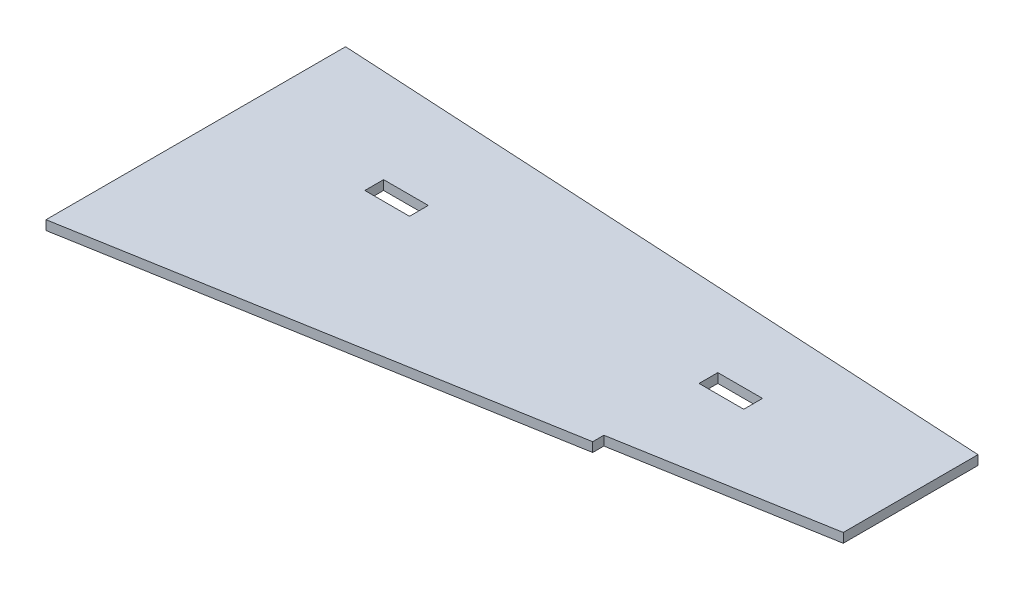
from build123d import *

# Parameters (mm, degrees)
BASE_DEPTH         = 5.334
CUT_EXTRUDE1_REACH = 7.334
SKETCH3_W          = 25.4
SKETCH3_H          = 10.668


with BuildPart() as part:
    # Sketch1 → Base (new body)
    with BuildSketch(Plane(origin=(0, 0, 0), x_dir=(1, 0, 0), z_dir=(0, 1, 0))):
        Polygon((0, 0), (380.417035208, -21.068443786), (380.417035208, -97.633742074), (264.564463463, -117.810081629), (264.564463463, -124.160081629), (0, -170.235385513), align=None)
    extrude(amount=BASE_DEPTH)

    # Sketch3 → Cut-Extrude1 (cut, up to next)
    with BuildSketch(Plane.XZ, mode=Mode.PRIVATE) as cut_extrude1_sk1:
        with Locations((278.817035208, 59.945526857)):
            Rectangle(SKETCH3_W, SKETCH3_H)
    cut_extrude1_tool1 = extrude(cut_extrude1_sk1.sketch, amount=-CUT_EXTRUDE1_REACH, mode=Mode.PRIVATE) & part.part
    add(cut_extrude1_tool1.solids().sort_by_distance((278.817035, 0, 59.945527))[0], mode=Mode.SUBTRACT)
    # Sketch3 → Cut-Extrude1 (cut, up to next)
    with BuildSketch(Plane.XZ, mode=Mode.PRIVATE) as cut_extrude1_sk2:
        with Locations((88.9, 59.945526857)):
            Rectangle(SKETCH3_W, SKETCH3_H)
    cut_extrude1_tool2 = extrude(cut_extrude1_sk2.sketch, amount=-CUT_EXTRUDE1_REACH, mode=Mode.PRIVATE) & part.part
    add(cut_extrude1_tool2.solids().sort_by_distance((88.9, 0, 59.945527))[0], mode=Mode.SUBTRACT)


solid = part.part
